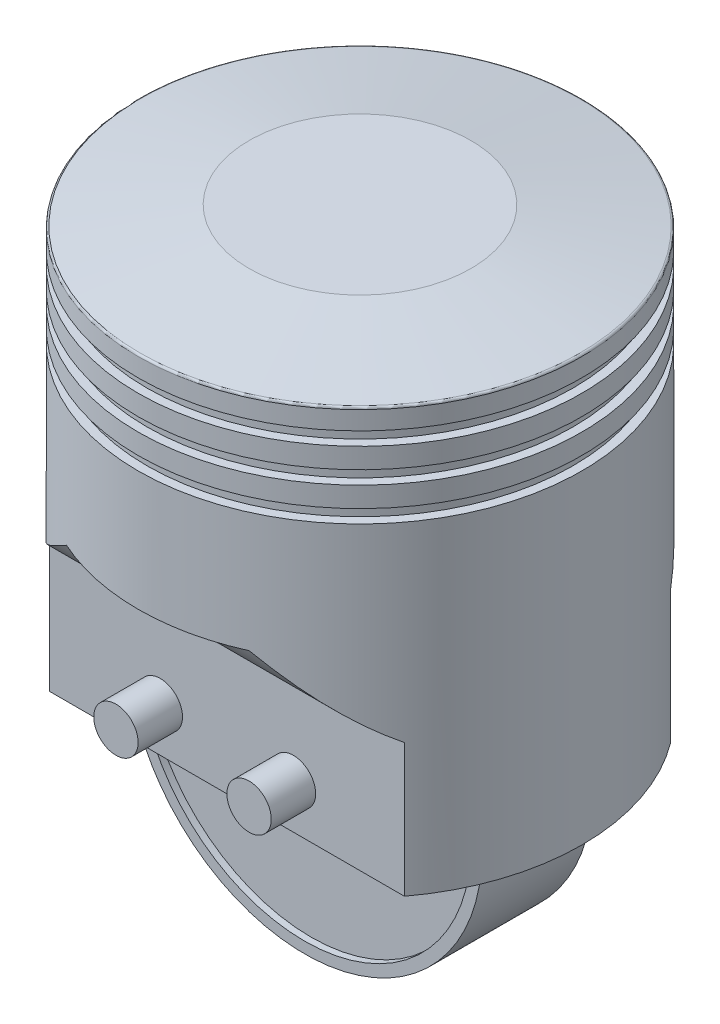
from build123d import *

# Parameters (mm, degrees)
CUT_EXTRUDE2_DEPTH       = 123.46632235
CUT_EXTRUDE2_DEPTH_BACK  = 123.46632235
BOSS_EXTRUDE3_DEPTH      = 12.5
BOSS_EXTRUDE3_DEPTH_BACK = 12.5
BOSS_EXTRUDE4_DEPTH      = 11
BOSS_EXTRUDE4_DEPTH_BACK = 11
BOSS_EXTRUDE5_DEPTH      = 40
BOSS_EXTRUDE5_DEPTH_BACK = 40
SKETCH4_8_R              = 5


with BuildPart() as part:
    # Sketch1 → Revolve2 (revolve)
    with BuildSketch(Plane.XY):
        with BuildLine():
            Line((-50, 0), (0, 0))
            Line((0, 0), (0, 95.74))
            Line((0, 95.74), (0, 99.99))
            Line((0, 99.99), (-25, 99.99))
            Line((-25, 99.99), (-49.583797747, 95.810754383))
            ThreePointArc((-49.583797747, 95.810754383), (-49.882033293, 95.640395155), (-50, 95.31782646))
            Line((-50, 95.31782646), (-50, 91.16))
            Line((-50, 91.16), (-48, 91.16))
            Line((-48, 91.16), (-48, 88.16))
            Line((-48, 88.16), (-50, 88.16))
            Line((-50, 88.16), (-50, 83.58))
            Line((-50, 83.58), (-48, 83.58))
            Line((-48, 83.58), (-48, 80.58))
            Line((-48, 80.58), (-50, 80.58))
            Line((-50, 80.58), (-50, 76))
            Line((-50, 76), (-48, 76))
            Line((-48, 76), (-48, 73))
            Line((-48, 73), (-50, 73))
            Line((-50, 73), (-50, 0))
        make_face()
    revolve(axis=Axis((0, 95.74, 0), (0, -1, 0)))

    # Sketch2 → Cut-Extrude2 (cut, two sides: drawn at the far end of the back side and taken through both)
    with BuildSketch(Plane(origin=(0, 0, 0), x_dir=(0, 0, -1), z_dir=(1, 0, 0)).offset(-CUT_EXTRUDE2_DEPTH_BACK)):
        with BuildLine():
            Line((30, 0), (30, 30))
            ThreePointArc((30, 30), (38.689431083, 37.119875503), (45.57, 46))
            Line((45.57, 46), (50, 46))
            Line((50, 46), (50, 0))
            Line((50, 0), (30, 0))
        make_face()
        with BuildLine():
            Line((-30, 0), (-30, 30))
            ThreePointArc((-30, 30), (-38.689431083, 37.119875503), (-45.57, 46))
            Line((-45.57, 46), (-50, 46))
            Line((-50, 46), (-50, 0))
            Line((-50, 0), (-30, 0))
        make_face()
    extrude(amount=CUT_EXTRUDE2_DEPTH + CUT_EXTRUDE2_DEPTH_BACK, mode=Mode.SUBTRACT)

    # Sketch4 → Boss-Extrude3 (add, two sides: drawn at the far end of the back side and taken through both)
    with BuildSketch(Plane.XY.offset(-BOSS_EXTRUDE3_DEPTH_BACK)):
        with BuildLine():
            Line((-40, 0), (40, 0))
            ThreePointArc((40, 0), (0, -40), (-40, 0))
        make_face()
        with BuildLine():
            Line((-37.416573868, -2.5), (37.416573868, -2.5))
            ThreePointArc((37.416573868, -2.5), (0, -37.5), (-37.416573868, -2.5))
        make_face(mode=Mode.SUBTRACT)
    extrude(amount=BOSS_EXTRUDE3_DEPTH + BOSS_EXTRUDE3_DEPTH_BACK)

    # Sketch4_7 → Boss-Extrude4 (add, two sides: drawn at the far end of the back side and taken through both)
    with BuildSketch(Plane.XY.offset(-BOSS_EXTRUDE4_DEPTH_BACK)):
        with BuildLine():
            Line((-37.416573868, -2.5), (37.416573868, -2.5))
            ThreePointArc((37.416573868, -2.5), (0, -37.5), (-37.416573868, -2.5))
        make_face()
    extrude(amount=BOSS_EXTRUDE4_DEPTH + BOSS_EXTRUDE4_DEPTH_BACK)

    # Sketch4_8 → Boss-Extrude5 (add, two sides: drawn at the far end of the back side and taken through both)
    with BuildSketch(Plane.XY.offset(-BOSS_EXTRUDE5_DEPTH_BACK)):
        with Locations((-15, 10)):
            Circle(SKETCH4_8_R)
        with Locations((15, 10)):
            Circle(SKETCH4_8_R)
    extrude(amount=BOSS_EXTRUDE5_DEPTH + BOSS_EXTRUDE5_DEPTH_BACK)


solid = part.part
